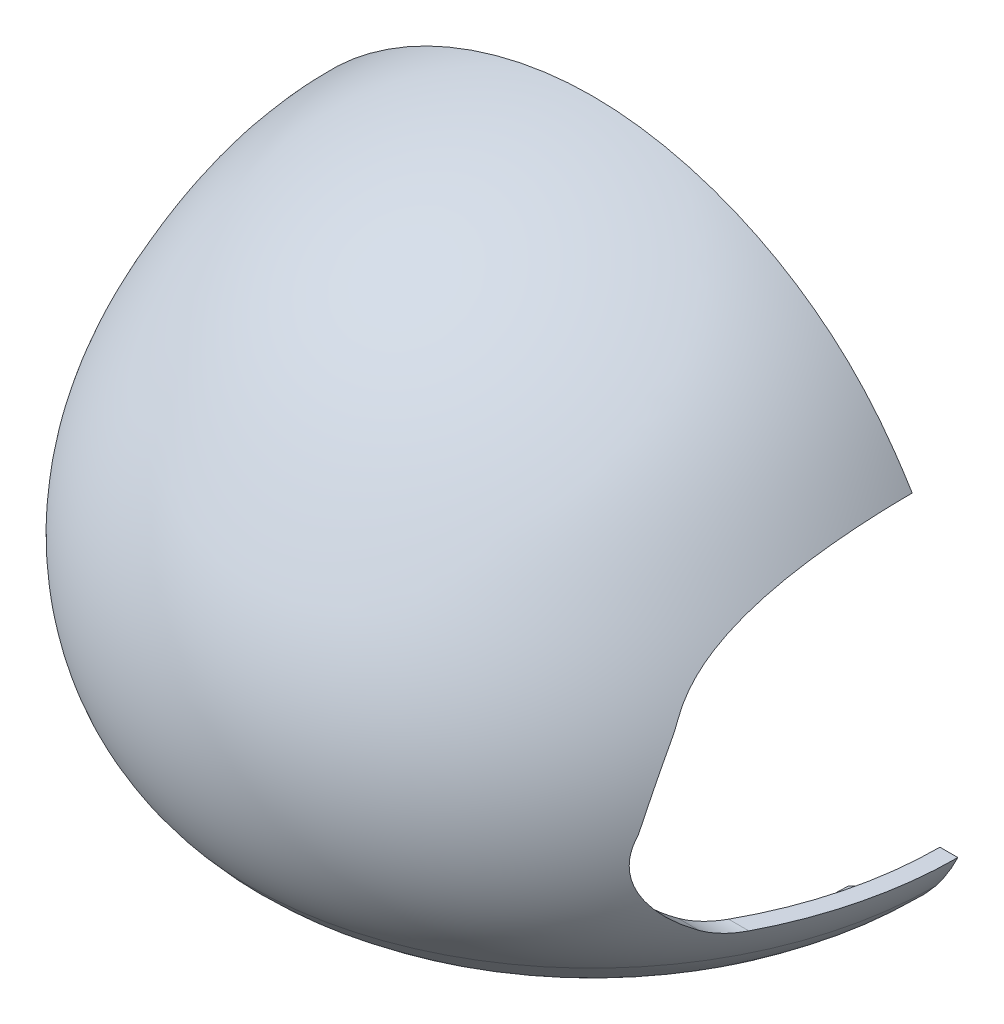
from build123d import *

# Parameters (mm, degrees)
SKETCH4_R           = 80.100145108
CUT_EXTRUDE2_DEPTH  = 20
CUT_EXTRUDE3_DEPTH  = 121.706010599
BOSS_EXTRUDE1_REACH = 54.085
SKETCH6_R           = 10
SKETCH7_W           = 348.912782296
SKETCH7_H           = 364.592796888
CUT_EXTRUDE4_DEPTH  = 159


with BuildPart() as part:
    # Sketch3 → Revolve5 (revolve)
    with BuildSketch(Plane.XY):
        with BuildLine():
            Line((0.02453969, 157.084900749), (0.02453969, 152.084900749))
            add(Edge.make_bspline(
                [(-103.174583613, -2.6432e-05), (-114.760245555, 14.576189089), (-119.836740195, 49.27275863), (-101.45175109, 88.673946708), (-71.379831841, 134.479430747), (-29.75001244, 152.084900749), (0.02453969, 152.084900749)],
                knots=[0, 0, 0, 0, 0.250738493, 0.442513363, 0.587644713, 1, 1, 1, 1], degree=3))
            add(Edge.make_bspline(
                [(-103.174583613, -2.6432e-05), (-78.832759046, -30.064140021), (-33.458723298, -20.943389124), (0.02453969, -20.943389124)],
                knots=[0, 0, 0, 0, 1, 1, 1, 1], degree=3))
            Line((0.02453969, -20.943389124), (0.02453969, -25.943389124))
            add(Edge.make_bspline(
                [(0.02453969, -25.943389124), (-1.007843071, -25.943389124), (-3.05274325, -25.960735741), (-7.300680211, -26.054029266), (-12.774839269, -26.259816275), (-19.586870399, -26.581007249), (-28.911339242, -27.014332449), (-40.900445748, -27.386982651), (-55.443773123, -26.975342887), (-69.789912797, -25.08625158), (-81.278725906, -21.722461367), (-89.959801918, -17.60281584), (-96.13825684, -13.717797758), (-100.945853349, -9.752185194), (-104.534382709, -6.13029221), (-106.254478554, -4.141899361), (-107.07473695, -3.128814187)],
                knots=[-0.000194385, -0.000194385, -0.000194385, -0.000194385, 0.03106169, 0.062317764, 0.124829913, 0.187342062, 0.249854211, 0.37487851, 0.499902808, 0.624927106, 0.749951404, 0.812463553, 0.874975702, 0.937487851, 0.968743925, 1, 1, 1, 1], degree=3))
            add(Edge.make_bspline(
                [(-107.07473695, -3.128814187), (-107.861659129, -2.138767408), (-109.375579618, -0.100482773), (-112.095489807, 4.115600278), (-114.955951775, 9.644100323), (-117.55365357, 16.585319153), (-119.962688147, 26.134623726), (-121.103112226, 38.406473215), (-119.79356064, 53.088411426), (-116.089945574, 67.047457773), (-110.633897624, 80.23296506), (-104.034329909, 92.718986198), (-96.815301706, 104.751602155), (-88.512248671, 116.246845317), (-78.667704424, 126.697829164), (-67.464684594, 135.71357688), (-55.182594106, 143.280590712), (-42.054195525, 149.310974483), (-28.321126938, 153.731407172), (-14.204212291, 156.457352496), (-4.722534611, 157.084900749), (0.02453969, 157.084900749)],
                knots=[-0.000101258, -0.000101258, -0.000101258, -0.000101258, 0.015525324, 0.031151906, 0.06240507, 0.093658235, 0.124911399, 0.187417728, 0.249924056, 0.312430385, 0.374936714, 0.437443042, 0.499949371, 0.562455699, 0.624962028, 0.687468357, 0.749974685, 0.812481014, 0.874987343, 0.937493671, 1, 1, 1, 1], degree=3))
        make_face()
    revolve(axis=Axis((0.02453969, 171.610282588, 0), (0, -1, 0)))

    # Sketch4 → Cut-Extrude2 (cut)
    with BuildSketch(Plane(origin=(0, -30, 0), x_dir=(1, 0, 0), z_dir=(0, 1, 0))):
        Circle(SKETCH4_R)
    extrude(amount=CUT_EXTRUDE2_DEPTH, mode=Mode.SUBTRACT)

    # Sketch5 → Cut-Extrude3 (cut, through all)
    with BuildSketch(Plane(origin=(0, 0, 0), x_dir=(0, 0, -1), z_dir=(1, 0, 0))):
        with BuildLine():
            Line((-52.476481645, 8.136577936), (52.476481645, 8.136577936))
            ThreePointArc((52.476481645, 8.136577936), (58.138069368, 8.954648303), (63.336499377, 11.341935492))
            add(Edge.make_bspline(
                [(63.336499377, 11.341935492), (82.622361185, 23.812864951), (78.746201445, 39.317958114)],
                knots=[5.637022825, 5.637022825, 5.637022825, 6.404500867, 6.404500867, 6.404500867], degree=2, weights=[1, 0.927271268, 1]))
            ThreePointArc((78.746201445, 39.317958114), (77.929706658, 42.769255575), (77.20089719, 46.240127895))
            add(Edge.make_bspline(
                [(70.494135614, 63.047069033), (72.356334923, 60.10156835), (75.045149162, 54.673263207), (76.692738831, 48.822390655), (77.20089719, 46.240127895)],
                knots=[0.168181527, 0.168181527, 0.168181527, 0.168181527, 0.552818848, 0.845617793, 0.845617793, 0.845617793, 0.845617793], degree=3))
            ThreePointArc((70.494135614, 63.047069033), (68.293855497, 66.646255249), (66.203011989, 70.31009851))
            add(Edge.make_bspline(
                [(66.203011989, 70.31009851), (-4.427969211, 198.528374497), (-67.022107814, 68.723719713)],
                knots=[0.328274459, 0.328274459, 0.328274459, 2.851830568, 2.851830568, 2.851830568], degree=2, weights=[1, 0.304123557, 1]))
            ThreePointArc((-67.022107814, 68.723719713), (-68.159373057, 66.423614108), (-69.341813393, 64.146402461))
            add(Edge.make_bspline(
                [(-69.341813393, 64.146402461), (-73.061653072, 57.152172395), (-75.898874077, 49.79082496), (-77.836559233, 42.105665134)],
                knots=[0.114274397, 0.114274397, 0.114274397, 0.114274397, 1, 1, 1, 1], degree=3))
            add(Edge.make_bspline(
                [(-77.836559233, 42.105665134), (-84.680776254, 25.143909909), (-63.336499377, 11.341935492)],
                knots=[2.947295522, 2.947295522, 2.947295522, 3.787755136, 3.787755136, 3.787755136], degree=2, weights=[1, 0.91299521, 1]))
            ThreePointArc((-63.336499377, 11.341935492), (-58.138069368, 8.954648303), (-52.476481645, 8.136577936))
        make_face()
    extrude(amount=CUT_EXTRUDE3_DEPTH, mode=Mode.SUBTRACT)

    # Sketch6 → Boss-Extrude1 (add, up to next)
    with BuildSketch(Plane(origin=(0, 105, 0), x_dir=(1, 0, 0), z_dir=(0, 1, 0)), mode=Mode.PRIVATE) as boss_extrude1_sk1:
        Circle(SKETCH6_R)
    boss_extrude1_tool1 = extrude(boss_extrude1_sk1.sketch, amount=BOSS_EXTRUDE1_REACH, mode=Mode.PRIVATE) - part.part
    add(boss_extrude1_tool1.solids().sort_by_distance((0, 105, 0))[0])

    # Sketch7 → Cut-Extrude4 (cut)
    with BuildSketch(Plane.XY):
        Rectangle(SKETCH7_W, SKETCH7_H)
    extrude(amount=-CUT_EXTRUDE4_DEPTH, mode=Mode.SUBTRACT)


solid = part.part
